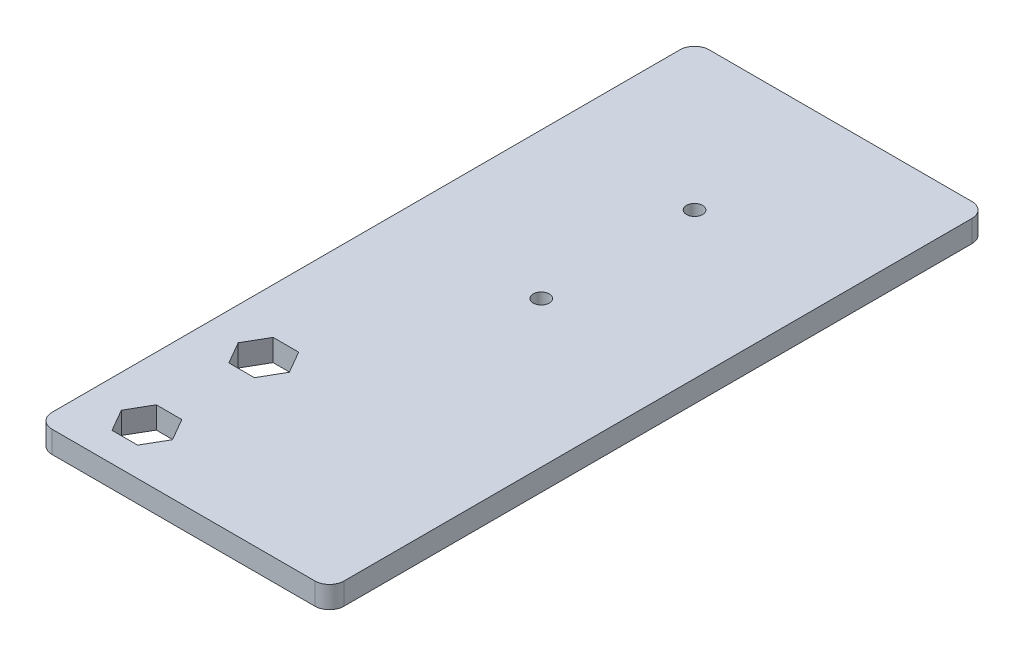
from build123d import *

# Parameters (mm, degrees)
EXTRUSION1_DEPTH        = 3
ESQUISSE2_R             = 1.1
ENL_V_MAT_EXTRU_1_DEPTH = 4
ESQUISSE3_R             = 1.1
ENL_V_MAT_EXTRU_2_DEPTH = 4


with BuildPart() as part:
    # Esquisse1 → Extrusion1 (new body)
    with BuildSketch(Plane(origin=(0, 0, 0), x_dir=(1, 0, 0), z_dir=(0, 1, 0))):
        with BuildLine():
            Line((13, 2), (13, 88))
            ThreePointArc((13, 88), (13.585786438, 89.414213562), (15, 90))
            Line((15, 90), (51, 90))
            ThreePointArc((51, 90), (52.414213562, 89.414213562), (53, 88))
            Line((53, 88), (53, 2))
            ThreePointArc((53, 2), (52.414213562, 0.585786438), (51, 0))
            Line((51, 0), (15, 0))
            ThreePointArc((15, 0), (13.585786438, 0.585786438), (13, 2))
        make_face()
    extrude(amount=EXTRUSION1_DEPTH)

    # Esquisse2 → Enlèv. mat.-Extru.1 (cut, through all)
    with BuildSketch(Plane.XZ):
        with Locations(Location((21, -7, 0), (0, 0, 90))):  # turned: the seam where the file's is
            Circle(ESQUISSE2_R)
        with Locations(Location((21, -23, 0), (0, 0, 90))):  # turned: the seam where the file's is
            Circle(ESQUISSE2_R)
    extrude(amount=-ENL_V_MAT_EXTRU_1_DEPTH, mode=Mode.SUBTRACT)

    # Esquisse3 → Enlèv. mat.-Extru.2 (cut, through all)
    with BuildSketch(Plane(origin=(0, 3, 0), x_dir=(1, 0, 0), z_dir=(0, 1, 0))):
        with Locations(Location((33, 70, 0), (0, 0, 270))):  # turned: the seam where the file's is
            Circle(ESQUISSE3_R)
        with Locations(Location((33, 49, 0), (0, 0, 270))):  # turned: the seam where the file's is
            Circle(ESQUISSE3_R)
        Polygon((17.5, 23), (19.25, 19.968911087), (22.75, 19.968911087), (24.5, 23), (22.75, 26.031088913), (19.25, 26.031088913), align=None)
        Polygon((17.5, 7), (19.25, 3.968911087), (22.75, 3.968911087), (24.5, 7), (22.75, 10.031088913), (19.25, 10.031088913), align=None)
    extrude(amount=-ENL_V_MAT_EXTRU_2_DEPTH, mode=Mode.SUBTRACT)


solid = part.part
